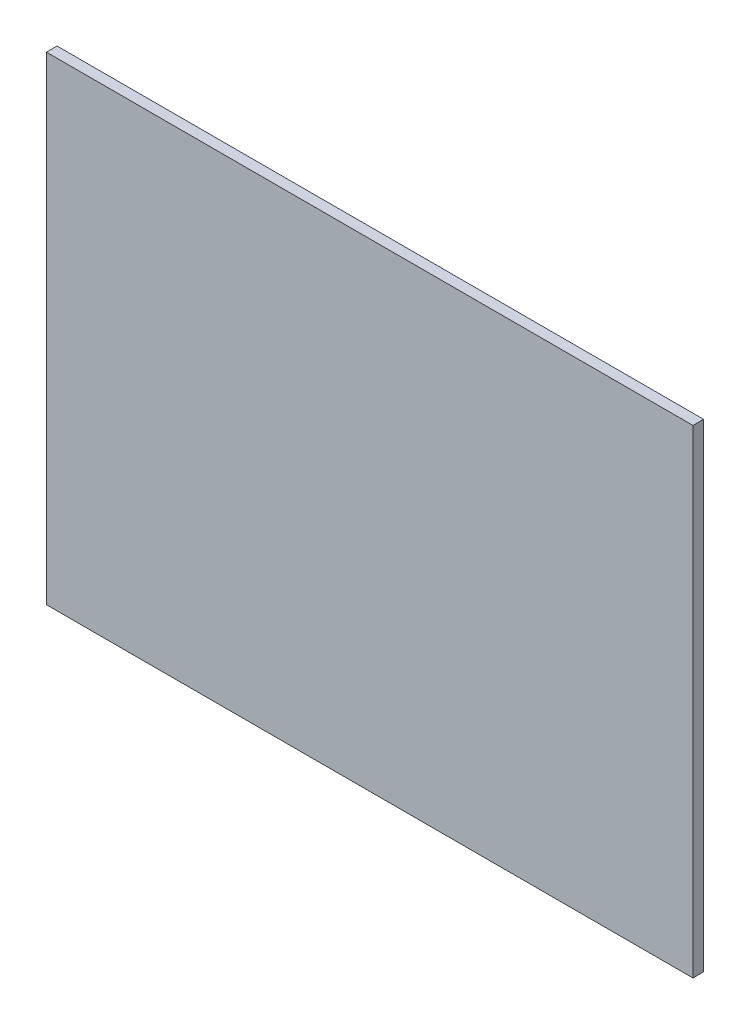
from build123d import *

# Parameters (mm, degrees)
SKETCH_1_W      = 304
SKETCH_1_H      = 225
EXTRUDE_1_DEPTH = 2.5


with BuildPart() as part:
    # 草图1 → 凸台-拉伸1 (new body, symmetric)
    with BuildSketch(Plane.XY):
        Rectangle(SKETCH_1_W, SKETCH_1_H)
    extrude(amount=EXTRUDE_1_DEPTH, both=True)


solid = part.part
